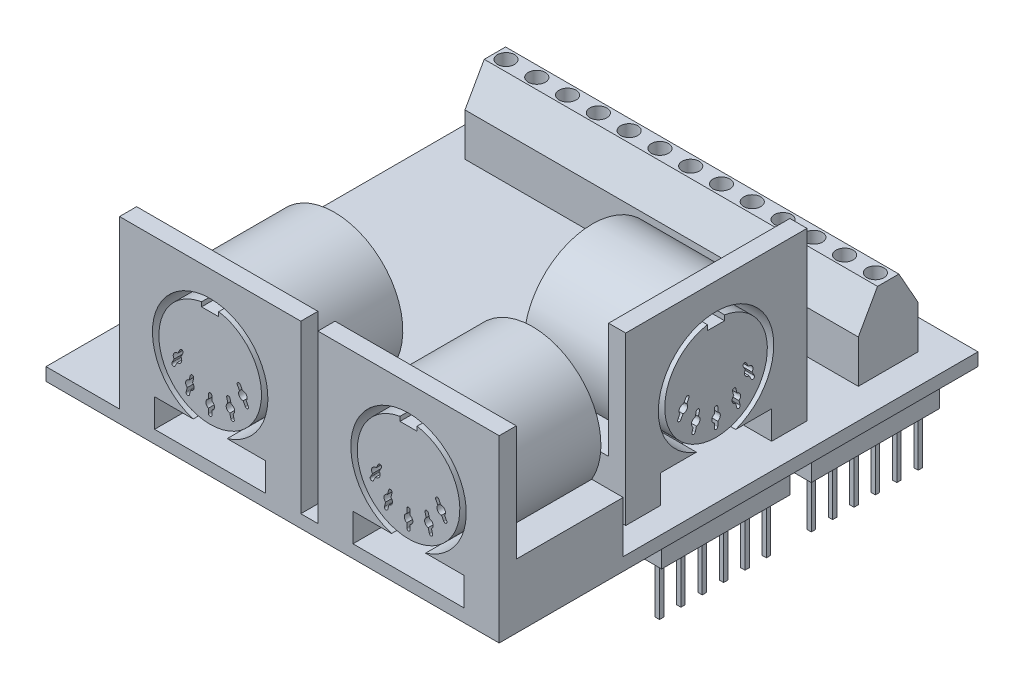
from build123d import *

# Parameters (mm, degrees)
SKETCH1_W             = 53
SKETCH1_H             = 56
BOSS_EXTRUDE1_DEPTH   = 1.5
SKETCH2_W             = 46
SKETCH2_H             = 7
BOSS_EXTRUDE2_DEPTH   = 5
BOSS_EXTRUDE3_DEPTH   = 46
SKETCH5_R             = 1
CUT_EXTRUDE1_DEPTH    = 2
SKETCH6_W             = 21.2
SKETCH6_H             = 19.5
BOSS_EXTRUDE4_DEPTH   = 2
BOSS_EXTRUDE4_2_DEPTH = 2
BOSS_EXTRUDE5_DEPTH   = 12.5
CUT_EXTRUDE2_DEPTH    = 5
BOSS_EXTRUDE6_START   = -3
SKETCH9_W             = 21.2
SKETCH9_H             = 19.5
BOSS_EXTRUDE6_DEPTH   = 2
BOSS_EXTRUDE7_DEPTH   = 12.5
CUT_EXTRUDE3_DEPTH    = 5
SKETCH14_W            = 2.5
SKETCH14_H            = 20
SKETCH14_H_2          = 15
BOSS_EXTRUDE8_DEPTH   = 3
SKETCH15_W            = 0.5
SKETCH15_H            = 0.5
BOSS_EXTRUDE9_DEPTH   = 6


with BuildPart() as part:
    # Sketch1 → Boss-Extrude1 (new body)
    with BuildSketch(Plane(origin=(0, 0, 0), x_dir=(1, 0, 0), z_dir=(0, 1, 0))):
        Rectangle(SKETCH1_W, SKETCH1_H)
    extrude(amount=BOSS_EXTRUDE1_DEPTH)

    # Sketch2 → Boss-Extrude2 (add)
    with BuildSketch(Plane(origin=(0, 1.5, 0), x_dir=(1, 0, 0), z_dir=(0, 1, 0))):
        with Locations((0, 21)):
            Rectangle(SKETCH2_W, SKETCH2_H)
    extrude(amount=BOSS_EXTRUDE2_DEPTH)

    # Sketch4 → Boss-Extrude3 (add)
    with BuildSketch(Plane.ZY.offset(23)):
        Polygon((-24.5, 6.5), (-17.5, 6.5), (-19.75, 10.5), (-22.25, 10.5), align=None)
    extrude(amount=-BOSS_EXTRUDE3_DEPTH)

    # Sketch5 → Cut-Extrude1 (cut)
    with BuildSketch(Plane(origin=(0, 10.5, 0), x_dir=(1, 0, 0), z_dir=(0, 1, 0))):
        with Locations(Location((-21.7, 21, 0), (0, 0, 270))):
            Circle(SKETCH5_R)
        with Locations(Location((-18.1, 21, 0), (0, 0, 270))):
            Circle(SKETCH5_R)
        with Locations(Location((-14.5, 21, 0), (0, 0, 270))):
            Circle(SKETCH5_R)
        with Locations(Location((-10.9, 21, 0), (0, 0, 270))):
            Circle(SKETCH5_R)
        with Locations(Location((-7.3, 21, 0), (0, 0, 270))):
            Circle(SKETCH5_R)
        with Locations(Location((-3.7, 21, 0), (0, 0, 270))):
            Circle(SKETCH5_R)
        with Locations(Location((-0.1, 21, 0), (0, 0, 270))):
            Circle(SKETCH5_R)
        with Locations(Location((3.5, 21, 0), (0, 0, 270))):
            Circle(SKETCH5_R)
        with Locations(Location((7.1, 21, 0), (0, 0, 270))):
            Circle(SKETCH5_R)
        with Locations(Location((10.7, 21, 0), (0, 0, 270))):
            Circle(SKETCH5_R)
        with Locations(Location((14.3, 21, 0), (0, 0, 270))):
            Circle(SKETCH5_R)
        with Locations(Location((17.9, 21, 0), (0, 0, 270))):
            Circle(SKETCH5_R)
        with Locations(Location((21.5, 21, 0), (0, 0, 270))):
            Circle(SKETCH5_R)
    extrude(amount=-CUT_EXTRUDE1_DEPTH, mode=Mode.SUBTRACT)



with BuildPart() as body_2:
    # Sketch6 → Boss-Extrude4 (new body)
    with BuildSketch(Plane.XY.offset(28)):
        with Locations((-7.3, 11.25)):
            Rectangle(SKETCH6_W, SKETCH6_H)
    extrude(amount=-BOSS_EXTRUDE4_DEPTH)


with BuildPart() as body_3:
    # Sketch6 → Boss-Extrude4 2 (new body)
    with BuildSketch(Plane.XY.offset(28)):
        with Locations((15.9, 11.25)):
            Rectangle(SKETCH6_W, SKETCH6_H)
    extrude(amount=-BOSS_EXTRUDE4_2_DEPTH)


with BuildPart() as part_1:
    add(part.part)

    add(body_2.part)  # Boss-Extrude5 merges body 2

    add(body_3.part)  # Boss-Extrude5 merges body 3
    # Sketch7 → Boss-Extrude5 (add)
    with BuildSketch(Plane(origin=(0, 0, 26), x_dir=(-1, 0, 0), z_dir=(0, 0, -1))):
        with BuildLine():
            Line((-26.5, 1.5), (-5.3, 1.5))
            Line((-5.3, 1.5), (-5.3, 7.5))
            Line((-5.3, 7.5), (-8.97179677, 7.5))
            ThreePointArc((-8.97179677, 7.5), (-15.9, 19.5), (-22.82820323, 7.5))
            Line((-22.82820323, 7.5), (-26.5, 7.5))
            Line((-26.5, 7.5), (-26.5, 1.5))
        make_face()
        with BuildLine():
            Line((17.9, 7.5), (14.199603605, 7.5))
            ThreePointArc((14.199603605, 7.5), (7.271400375, 19.5), (0.343197145, 7.5))
            Line((0.343197145, 7.5), (-3.3, 7.5))
            Line((-3.3, 7.5), (-3.3, 1.5))
            Line((-3.3, 1.5), (17.9, 1.5))
            Line((17.9, 1.5), (17.9, 7.5))
        make_face()
    extrude(amount=BOSS_EXTRUDE5_DEPTH)

    # Sketch8 → Cut-Extrude2 (cut)
    with BuildSketch(Plane.XY.offset(28)):
        with BuildLine():
            Line((22.4, 4.8), (17.889974874, 4.8))
            ThreePointArc((17.889974874, 4.8), (15.9, 18), (13.910025126, 4.8))
            Line((13.910025126, 4.8), (9.4, 4.8))
            Line((9.4, 4.8), (9.4, 1.5))
            Line((9.4, 1.5), (22.4, 1.5))
            Line((22.4, 1.5), (22.4, 4.8))
        make_face()
        with BuildLine():
            Line((14.9, 16.65), (16.9, 16.65))
            Line((16.9, 16.65), (16.9, 17.166079783))
            ThreePointArc((16.9, 17.166079783), (15.9, 5.25), (14.9, 17.166079783))
            Line((14.9, 17.166079783), (14.9, 16.65))
        make_face(mode=Mode.SUBTRACT)
        with BuildLine():
            Line((12.37138919, 11.046533528), (12.11684016, 10.568318459))
            ThreePointArc((12.11684016, 10.568318459), (11.636697705, 10.304759694), (11.686196321, 9.759278359))
            Line((11.686196321, 9.759278359), (11.43164729, 9.28106329))
            ThreePointArc((11.43164729, 9.28106329), (11.514220124, 9.010542076), (11.784741338, 9.09311491))
            Line((11.784741338, 9.09311491), (12.039290368, 9.571329979))
            ThreePointArc((12.039290368, 9.571329979), (12.519432824, 9.834888744), (12.469934207, 10.380370079))
            Line((12.469934207, 10.380370079), (12.724483238, 10.858585148))
            ThreePointArc((12.724483238, 10.858585148), (12.641910404, 11.129106362), (12.37138919, 11.046533528))
        make_face()
        with BuildLine():
            Line((13.580989238, 9.049527067), (13.445845832, 8.524911855))
            ThreePointArc((13.445845832, 8.524911855), (13.04101313, 8.155980313), (13.217211393, 7.637372395))
            Line((13.217211393, 7.637372395), (13.082067987, 7.112757183))
            ThreePointArc((13.082067987, 7.112757183), (13.225852851, 6.869188069), (13.469421964, 7.012972933))
            Line((13.469421964, 7.012972933), (13.60456537, 7.537588145))
            ThreePointArc((13.60456537, 7.537588145), (14.009398072, 7.906519687), (13.833199809, 8.425127605))
            Line((13.833199809, 8.425127605), (13.968343215, 8.949742817))
            ThreePointArc((13.968343215, 8.949742817), (13.824558351, 9.193311931), (13.580989238, 9.049527067))
        make_face()
        with BuildLine():
            Line((15.7, 8.25), (15.7, 7.708257569))
            ThreePointArc((15.7, 7.708257569), (15.4, 7.25), (15.7, 6.791742431))
            Line((15.7, 6.791742431), (15.7, 6.25))
            ThreePointArc((15.7, 6.25), (15.9, 6.05), (16.1, 6.25))
            Line((16.1, 6.25), (16.1, 6.791742431))
            ThreePointArc((16.1, 6.791742431), (16.4, 7.25), (16.1, 7.708257569))
            Line((16.1, 7.708257569), (16.1, 8.25))
            ThreePointArc((16.1, 8.25), (15.9, 8.45), (15.7, 8.25))
        make_face()
        with BuildLine():
            Line((17.831656785, 8.949742817), (17.966800191, 8.425127605))
            ThreePointArc((17.966800191, 8.425127605), (17.790601928, 7.906519687), (18.19543463, 7.537588145))
            Line((18.19543463, 7.537588145), (18.330578036, 7.012972933))
            ThreePointArc((18.330578036, 7.012972933), (18.574147149, 6.869188069), (18.717932013, 7.112757183))
            Line((18.717932013, 7.112757183), (18.582788607, 7.637372395))
            ThreePointArc((18.582788607, 7.637372395), (18.75898687, 8.155980313), (18.354154168, 8.524911855))
            Line((18.354154168, 8.524911855), (18.219010762, 9.049527067))
            ThreePointArc((18.219010762, 9.049527067), (17.975441649, 9.193311931), (17.831656785, 8.949742817))
        make_face()
        with BuildLine():
            Line((19.075516762, 10.858585148), (19.330065793, 10.380370079))
            ThreePointArc((19.330065793, 10.380370079), (19.280567176, 9.834888744), (19.760709632, 9.571329979))
            Line((19.760709632, 9.571329979), (20.015258662, 9.09311491))
            ThreePointArc((20.015258662, 9.09311491), (20.285779876, 9.010542076), (20.36835271, 9.28106329))
            Line((20.36835271, 9.28106329), (20.113803679, 9.759278359))
            ThreePointArc((20.113803679, 9.759278359), (20.163302295, 10.304759694), (19.68315984, 10.568318459))
            Line((19.68315984, 10.568318459), (19.42861081, 11.046533528))
            ThreePointArc((19.42861081, 11.046533528), (19.158089596, 11.129106362), (19.075516762, 10.858585148))
        make_face()
        with BuildLine():
            Line((-13.8, 4.8), (-13.8, 1.5))
            Line((-13.8, 1.5), (-0.8, 1.5))
            Line((-0.8, 1.5), (-0.8, 4.8))
            Line((-0.8, 4.8), (-5.310025126, 4.8))
            ThreePointArc((-5.310025126, 4.8), (-7.3, 18), (-9.289974874, 4.8))
            Line((-9.289974874, 4.8), (-13.8, 4.8))
        make_face()
        with BuildLine():
            Line((-8.3, 17.166079783), (-8.3, 16.65))
            Line((-8.3, 16.65), (-6.3, 16.65))
            Line((-6.3, 16.65), (-6.3, 17.166079783))
            ThreePointArc((-6.3, 17.166079783), (-7.3, 5.25), (-8.3, 17.166079783))
        make_face(mode=Mode.SUBTRACT)
        with BuildLine():
            Line((-11.513803679, 9.759278359), (-11.76835271, 9.28106329))
            ThreePointArc((-11.76835271, 9.28106329), (-11.685779876, 9.010542076), (-11.415258662, 9.09311491))
            Line((-11.415258662, 9.09311491), (-11.160709632, 9.571329979))
            ThreePointArc((-11.160709632, 9.571329979), (-10.680567176, 9.834888744), (-10.730065793, 10.380370079))
            Line((-10.730065793, 10.380370079), (-10.475516762, 10.858585148))
            ThreePointArc((-10.475516762, 10.858585148), (-10.558089596, 11.129106362), (-10.82861081, 11.046533528))
            Line((-10.82861081, 11.046533528), (-11.08315984, 10.568318459))
            ThreePointArc((-11.08315984, 10.568318459), (-11.563302295, 10.304759694), (-11.513803679, 9.759278359))
        make_face()
        with BuildLine():
            Line((-9.982788607, 7.637372395), (-10.117932013, 7.112757183))
            ThreePointArc((-10.117932013, 7.112757183), (-9.974147149, 6.869188069), (-9.730578036, 7.012972933))
            Line((-9.730578036, 7.012972933), (-9.59543463, 7.537588145))
            ThreePointArc((-9.59543463, 7.537588145), (-9.190601928, 7.906519687), (-9.366800191, 8.425127605))
            Line((-9.366800191, 8.425127605), (-9.231656785, 8.949742817))
            ThreePointArc((-9.231656785, 8.949742817), (-9.375441649, 9.193311931), (-9.619010762, 9.049527067))
            Line((-9.619010762, 9.049527067), (-9.754154168, 8.524911855))
            ThreePointArc((-9.754154168, 8.524911855), (-10.15898687, 8.155980313), (-9.982788607, 7.637372395))
        make_face()
        with BuildLine():
            Line((-3.439290368, 9.571329979), (-3.184741338, 9.09311491))
            ThreePointArc((-3.184741338, 9.09311491), (-2.914220124, 9.010542076), (-2.83164729, 9.28106329))
            Line((-2.83164729, 9.28106329), (-3.086196321, 9.759278359))
            ThreePointArc((-3.086196321, 9.759278359), (-3.036697705, 10.304759694), (-3.51684016, 10.568318459))
            Line((-3.51684016, 10.568318459), (-3.77138919, 11.046533528))
            ThreePointArc((-3.77138919, 11.046533528), (-4.041910404, 11.129106362), (-4.124483238, 10.858585148))
            Line((-4.124483238, 10.858585148), (-3.869934207, 10.380370079))
            ThreePointArc((-3.869934207, 10.380370079), (-3.919432824, 9.834888744), (-3.439290368, 9.571329979))
        make_face()
        with BuildLine():
            Line((-5.00456537, 7.537588145), (-4.869421964, 7.012972933))
            ThreePointArc((-4.869421964, 7.012972933), (-4.625852851, 6.869188069), (-4.482067987, 7.112757183))
            Line((-4.482067987, 7.112757183), (-4.617211393, 7.637372395))
            ThreePointArc((-4.617211393, 7.637372395), (-4.44101313, 8.155980313), (-4.845845832, 8.524911855))
            Line((-4.845845832, 8.524911855), (-4.980989238, 9.049527067))
            ThreePointArc((-4.980989238, 9.049527067), (-5.224558351, 9.193311931), (-5.368343215, 8.949742817))
            Line((-5.368343215, 8.949742817), (-5.233199809, 8.425127605))
            ThreePointArc((-5.233199809, 8.425127605), (-5.409398072, 7.906519687), (-5.00456537, 7.537588145))
        make_face()
        with BuildLine():
            Line((-7.5, 6.791742431), (-7.5, 6.25))
            ThreePointArc((-7.5, 6.25), (-7.3, 6.05), (-7.1, 6.25))
            Line((-7.1, 6.25), (-7.1, 6.791742431))
            ThreePointArc((-7.1, 6.791742431), (-6.8, 7.25), (-7.1, 7.708257569))
            Line((-7.1, 7.708257569), (-7.1, 8.25))
            ThreePointArc((-7.1, 8.25), (-7.3, 8.45), (-7.5, 8.25))
            Line((-7.5, 8.25), (-7.5, 7.708257569))
            ThreePointArc((-7.5, 7.708257569), (-7.8, 7.25), (-7.5, 6.791742431))
        make_face()
    extrude(amount=-CUT_EXTRUDE2_DEPTH, mode=Mode.SUBTRACT)



with BuildPart() as body_2_2:
    # Sketch9 → Boss-Extrude6 (new body)
    with BuildSketch(Plane(origin=(26.5, 0, 0), x_dir=(0, 0, -1), z_dir=(1, 0, 0)).offset(BOSS_EXTRUDE6_START)):
        with Locations((0.4, 11.25)):
            Rectangle(SKETCH9_W, SKETCH9_H)
    extrude(amount=-BOSS_EXTRUDE6_DEPTH)


with BuildPart() as part_2:
    add(part_1.part)

    add(body_2_2.part)  # Boss-Extrude7 merges body 2 2
    # Sketch11 → Boss-Extrude7 (add)
    with BuildSketch(Plane.ZY.offset(-21.5)):
        with BuildLine():
            Line((-11, 1.5), (10.2, 1.5))
            Line((10.2, 1.5), (10.2, 7.5))
            Line((10.2, 7.5), (6.52820323, 7.5))
            ThreePointArc((6.52820323, 7.5), (-0.4, 19.5), (-7.32820323, 7.5))
            Line((-7.32820323, 7.5), (-11, 7.5))
            Line((-11, 7.5), (-11, 1.5))
        make_face()
    extrude(amount=BOSS_EXTRUDE7_DEPTH)

    # Sketch13 → Cut-Extrude3 (cut)
    with BuildSketch(Plane(origin=(23.5, 0, 0), x_dir=(0, 0, -1), z_dir=(1, 0, 0))):
        with BuildLine():
            Line((-6.136759584, 1.5), (-6.1, 1.5))
            Line((-6.1, 1.5), (6.826480832, 1.5))
            Line((6.826480832, 1.5), (6.863240416, 1.5))
            Line((6.863240416, 1.5), (6.863240416, 4.8))
            Line((6.863240416, 4.8), (2.660632151, 4.8))
            ThreePointArc((2.660632151, 4.8), (0.363240416, 17.897006477), (-1.934151319, 4.8))
            Line((-1.934151319, 4.8), (-6.136759584, 4.8))
            Line((-6.136759584, 4.8), (-6.136759584, 1.5))
        make_face()
        with BuildLine():
            Line((-0.636759584, 17.06308626), (-0.636759584, 16.463097099))
            Line((-0.636759584, 16.463097099), (1.363240416, 16.463097099))
            Line((1.363240416, 16.463097099), (1.363240416, 17.06308626))
            ThreePointArc((1.363240416, 17.06308626), (0.363240416, 5.147006477), (-0.636759584, 17.06308626))
        make_face(mode=Mode.SUBTRACT)
        with BuildLine():
            Line((-2.089744811, 8.422104829), (-1.951875082, 8.952329562))
            ThreePointArc((-1.951875082, 8.952329562), (-1.706657415, 9.088855843), (-1.566380483, 8.845764272))
            Line((-1.566380483, 8.845764272), (-1.702687015, 8.321450063))
            ThreePointArc((-1.702687015, 8.321450063), (-1.527639322, 7.802452659), (-1.933289222, 7.434419837))
            Line((-1.933289222, 7.434419837), (-2.069595755, 6.910105627))
            ThreePointArc((-2.069595755, 6.910105627), (-2.3134877, 6.766862474), (-2.456725116, 7.010757788))
            Line((-2.456725116, 7.010757788), (-2.320399083, 7.535045714))
            ThreePointArc((-2.320399083, 7.535045714), (-2.495462725, 8.054083061), (-2.089744811, 8.422104829))
        make_face()
        with BuildLine():
            Line((-3.756792421, 8.991567899), (-3.499907193, 9.468532091))
            ThreePointArc((-3.499907193, 9.468532091), (-3.018481254, 9.729739032), (-3.065310995, 10.275455969))
            Line((-3.065310995, 10.275455969), (-2.808425767, 10.752420161))
            ThreePointArc((-2.808425767, 10.752420161), (-2.89253494, 11.024853014), (-3.163571673, 10.936348201))
            Line((-3.163571673, 10.936348201), (-3.417367655, 10.465119875))
            ThreePointArc((-3.417367655, 10.465119875), (-3.898907386, 10.203922359), (-3.852007156, 9.658115596))
            Line((-3.852007156, 9.658115596), (-4.105803139, 9.18688727))
            ThreePointArc((-4.105803139, 9.18688727), (-4.030550111, 8.911876372), (-3.756792421, 8.991567899))
        make_face()
        with BuildLine():
            Line((0.563137024, 6.153436571), (0.563137024, 6.688703797))
            ThreePointArc((0.563137024, 6.688703797), (0.863240416, 7.147006477), (0.563137024, 7.605309156))
            Line((0.563137024, 7.605309156), (0.563137024, 8.153436571))
            ThreePointArc((0.563137024, 8.153436571), (0.362999363, 8.347006332), (0.163328889, 8.152954697))
            Line((0.163328889, 8.152954697), (0.163328889, 7.605302649))
            ThreePointArc((0.163328889, 7.605302649), (-0.136759584, 7.147012979), (0.16331697, 6.688715504))
            Line((0.16331697, 6.688715504), (0.16331697, 6.15253962))
            ThreePointArc((0.16331697, 6.15253962), (0.363689092, 5.94700698), (0.563137024, 6.153436571))
        make_face()
        with BuildLine():
            Line((2.436616544, 8.327188835), (2.286594352, 8.904261451))
            ThreePointArc((2.286594352, 8.904261451), (2.471523256, 9.095529709), (2.682825488, 8.933870771))
            Line((2.682825488, 8.933870771), (2.815854599, 8.422163433))
            ThreePointArc((2.815854599, 8.422163433), (3.221949476, 8.054060295), (3.046547392, 7.534784762))
            Line((3.046547392, 7.534784762), (3.18604076, 6.998212126))
            ThreePointArc((3.18604076, 6.998212126), (3.009724755, 6.761437956), (2.78965476, 6.958208226))
            Line((2.78965476, 6.958208226), (2.666103661, 7.43345762))
            ThreePointArc((2.666103661, 7.43345762), (2.253745315, 7.803903428), (2.436616544, 8.327188835))
        make_face()
        with BuildLine():
            Line((3.791791827, 10.275455969), (3.534906599, 10.752420161))
            ThreePointArc((3.534906599, 10.752420161), (3.616155159, 11.023342053), (3.887077051, 10.942093492))
            Line((3.887077051, 10.942093492), (4.143962279, 10.4651293))
            ThreePointArc((4.143962279, 10.4651293), (4.625388217, 10.203922359), (4.578558477, 9.658205422))
            Line((4.578558477, 9.658205422), (4.835443705, 9.18124123))
            ThreePointArc((4.835443705, 9.18124123), (4.746019893, 8.906155295), (4.475324473, 9.008100767))
            Line((4.475324473, 9.008100767), (4.227302396, 9.468608561))
            ThreePointArc((4.227302396, 9.468608561), (3.745179818, 9.729335209), (3.791791827, 10.275455969))
        make_face()
    extrude(amount=-CUT_EXTRUDE3_DEPTH, mode=Mode.SUBTRACT)

    # Sketch14 → Boss-Extrude8 (add)
    with BuildSketch(Plane.XZ):
        with Locations((-24.25, 8)):
            Rectangle(SKETCH14_W, SKETCH14_H)
        with Locations((24.25, 0.5)):
            Rectangle(SKETCH14_W, SKETCH14_H_2)
        with Locations((24.25, -17)):
            Rectangle(SKETCH14_W, SKETCH14_H_2)
        with Locations((-24.25, -14.5)):
            Rectangle(SKETCH14_W, SKETCH14_H)
    extrude(amount=BOSS_EXTRUDE8_DEPTH)

    # Sketch15 → Boss-Extrude9 (add)
    with BuildSketch(Plane.XZ.offset(3)):
        with Locations((24.25, 4.5)):
            Rectangle(SKETCH15_W, SKETCH15_H)
        with Locations((24.25, 7)):
            Rectangle(SKETCH15_W, SKETCH15_H)
        with Locations((24.25, 2)):
            Rectangle(SKETCH15_W, SKETCH15_H)
        with Locations((24.25, -0.5)):
            Rectangle(SKETCH15_W, SKETCH15_H)
        with Locations((24.25, -3)):
            Rectangle(SKETCH15_W, SKETCH15_H)
        with Locations((24.25, -5.5)):
            Rectangle(SKETCH15_W, SKETCH15_H)
        with Locations((24.25, -10.75)):
            Rectangle(SKETCH15_W, SKETCH15_H)
        with Locations((24.25, -13.25)):
            Rectangle(SKETCH15_W, SKETCH15_H)
        with Locations((24.25, -15.75)):
            Rectangle(SKETCH15_W, SKETCH15_H)
        with Locations((24.25, -18.25)):
            Rectangle(SKETCH15_W, SKETCH15_H)
        with Locations((24.25, -20.75)):
            Rectangle(SKETCH15_W, SKETCH15_H)
        with Locations((24.25, -23.25)):
            Rectangle(SKETCH15_W, SKETCH15_H)
        with Locations((-24.25, 14.25)):
            Rectangle(SKETCH15_W, SKETCH15_H)
        with Locations((-24.25, 16.75)):
            Rectangle(SKETCH15_W, SKETCH15_H)
        with Locations((-24.25, 11.75)):
            Rectangle(SKETCH15_W, SKETCH15_H)
        with Locations((-24.25, 9.25)):
            Rectangle(SKETCH15_W, SKETCH15_H)
        with Locations((-24.25, 6.75)):
            Rectangle(SKETCH15_W, SKETCH15_H)
        with Locations((-24.25, 4.25)):
            Rectangle(SKETCH15_W, SKETCH15_H)
        with Locations((-24.25, 1.75)):
            Rectangle(SKETCH15_W, SKETCH15_H)
        with Locations((-24.25, -0.75)):
            Rectangle(SKETCH15_W, SKETCH15_H)
        with Locations((-24.25, -5.75)):
            Rectangle(SKETCH15_W, SKETCH15_H)
        with Locations((-24.25, -8.25)):
            Rectangle(SKETCH15_W, SKETCH15_H)
        with Locations((-24.25, -10.75)):
            Rectangle(SKETCH15_W, SKETCH15_H)
        with Locations((-24.25, -13.25)):
            Rectangle(SKETCH15_W, SKETCH15_H)
        with Locations((-24.25, -15.75)):
            Rectangle(SKETCH15_W, SKETCH15_H)
        with Locations((-24.25, -18.25)):
            Rectangle(SKETCH15_W, SKETCH15_H)
        with Locations((-24.25, -20.75)):
            Rectangle(SKETCH15_W, SKETCH15_H)
        with Locations((-24.25, -23.25)):
            Rectangle(SKETCH15_W, SKETCH15_H)
    extrude(amount=BOSS_EXTRUDE9_DEPTH)


solid = part_2.part
